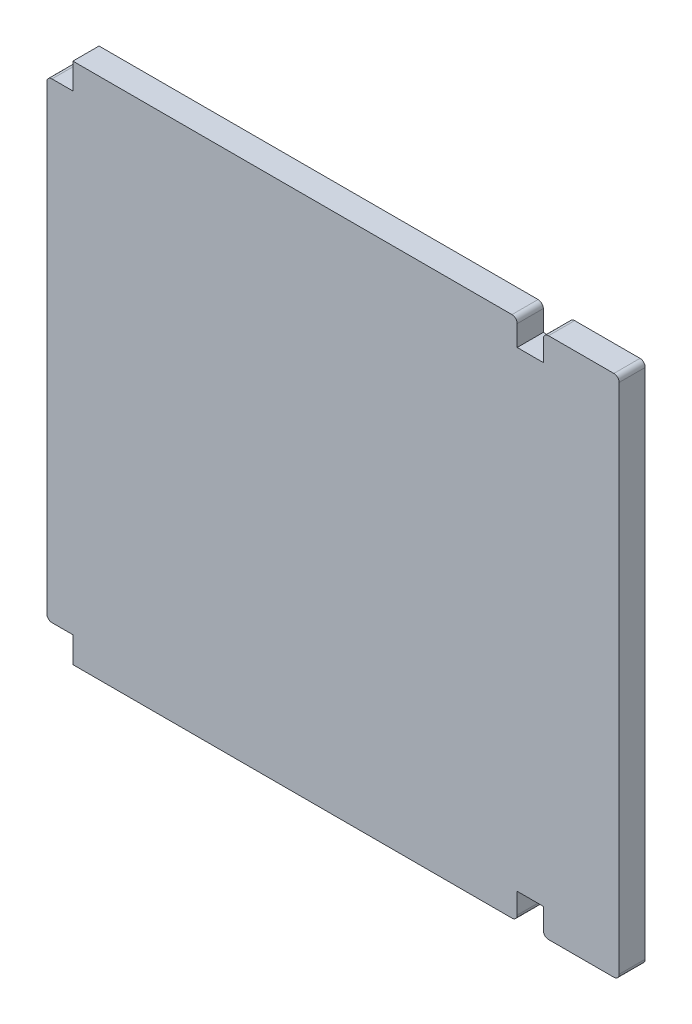
from build123d import *

# Parameters (mm, degrees)
BOSS_EXTRUDE1_DEPTH = 5
FILLET1_R           = 1


with BuildPart() as part:
    # Sketch1 → Boss-Extrude1 (new body)
    with BuildSketch(Plane.XY):
        Polygon((0, 95.05), (0, 100), (85, 100), (85, 95.05), (90, 95.05), (90, 100), (104.5, 100), (104.5, -0.05), (90, -0.05), (90, 4.95), (85, 4.95), (85, 0), (0, 0), (0, 4.95), (-5, 4.95), (-5, 95.05), align=None)
    extrude(amount=BOSS_EXTRUDE1_DEPTH)

    # Fillet1
    fillet1_edges = [part.edges().sort_by_distance(p)[0] for p in [
        (-5, 4.95, 2.5),
        (-5, 95.05, 2.5),
        (85, 100, 2.5),
        (90, 100, 2.5),
        (104.5, 100, 2.5),
        (104.5, -0.05, 2.5),
        (90, -0.05, 2.5),
        (85, 0, 2.5),
    ]]
    fillet(fillet1_edges, radius=FILLET1_R)


solid = part.part
